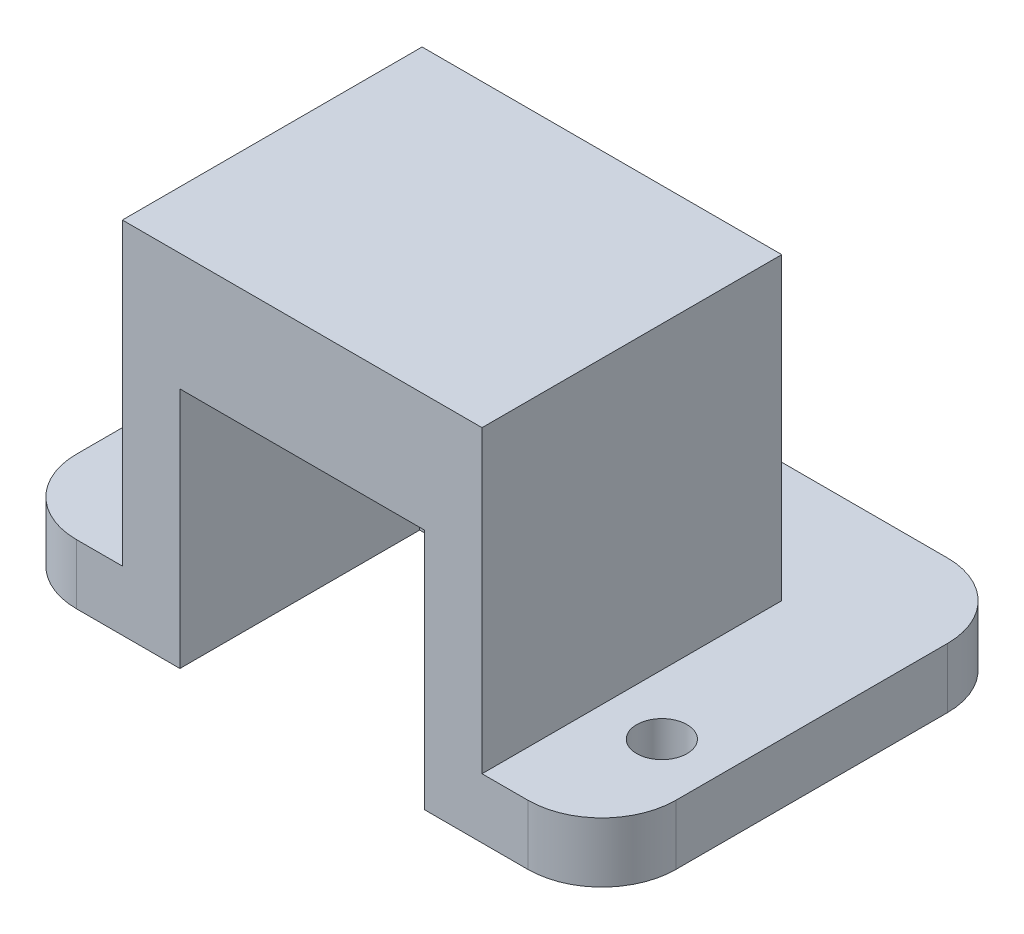
from build123d import *

# Parameters (mm, degrees)
SKETCH_1_W          = 30
SKETCH_1_H          = 30
EXTRUDE_1_DEPTH     = 5
SKETCH_2_W          = 30
SKETCH_2_H          = 5
EXTRUDE_2_DEPTH     = 10
SKETCH_3_R          = 2.1
CUT_EXTRUDE_1_DEPTH = 5
EXTRUDE_3_DEPTH     = 20
SKETCH_5_W          = 35
SKETCH_5_H          = 5
EXTRUDE_4_DEPTH     = 10
SKETCH_6_W          = 35
SKETCH_6_H          = 5
EXTRUDE_5_DEPTH     = 10
SKETCH_7_R          = 2.1
CUT_EXTRUDE_2_DEPTH = 10
FILLET_1_R          = 6.17
FILLET_2_R          = 6.17
FILLET_3_R          = 6.17
FILLET_4_R          = 6.17


with BuildPart() as part:
    # 스케치1 → 보스-돌출1 (new body)
    with BuildSketch(Plane.XY):
        Rectangle(SKETCH_1_W, SKETCH_1_H)
    extrude(amount=EXTRUDE_1_DEPTH)

    # 스케치2 → 보스-돌출2 (add)
    with BuildSketch(Plane(origin=(0, 0, 0), x_dir=(-1, 0, 0), z_dir=(0, 0, -1))):
        with Locations((0, -12.5)):
            Rectangle(SKETCH_2_W, SKETCH_2_H)
    extrude(amount=EXTRUDE_2_DEPTH)

    # 스케치3 → 컷-돌출1 (cut)
    with BuildSketch(Plane(origin=(0, -10, 0), x_dir=(1, 0, 0), z_dir=(0, 1, 0))):
        with Locations((0, 5)):
            Circle(SKETCH_3_R)
    extrude(amount=-CUT_EXTRUDE_1_DEPTH, mode=Mode.SUBTRACT)

    # 스케치4 → 보스-돌출3 (add)
    with BuildSketch(Plane.XY.offset(5)):
        Polygon((10.2, -15), (15, -15), (15, 15), (-15, 15), (-15, -15), (-10.2, -15), (-10.2, 5.2), (10.2, 5.2), align=None)
    extrude(amount=EXTRUDE_3_DEPTH)

    # 스케치5 → 보스-돌출4 (add)
    with BuildSketch(Plane.ZY.offset(15)):
        with Locations((7.5, -12.5)):
            Rectangle(SKETCH_5_W, SKETCH_5_H)
    extrude(amount=EXTRUDE_4_DEPTH)

    # 스케치6 → 보스-돌출5 (add)
    with BuildSketch(Plane(origin=(15, 0, 0), x_dir=(0, 0, -1), z_dir=(1, 0, 0))):
        with Locations((-7.5, -12.5)):
            Rectangle(SKETCH_6_W, SKETCH_6_H)
    extrude(amount=EXTRUDE_5_DEPTH)

    # 스케치7 → 컷-돌출2 (cut)
    with BuildSketch(Plane(origin=(0, -10, 0), x_dir=(1, 0, 0), z_dir=(0, 1, 0))):
        with Locations((-20, -15)):
            Circle(SKETCH_7_R)
        with Locations((20, -15)):
            Circle(SKETCH_7_R)
    extrude(amount=-CUT_EXTRUDE_2_DEPTH, mode=Mode.SUBTRACT)

    # 필렛1
    fillet_1_edges = [part.edges().sort_by_distance(p)[0] for p in [
        (25, -12.5, 25),
    ]]
    fillet(fillet_1_edges, radius=FILLET_1_R)

    # 필렛2
    fillet_2_edges = [part.edges().sort_by_distance(p)[0] for p in [
        (25, -12.5, -10),
    ]]
    fillet(fillet_2_edges, radius=FILLET_2_R)

    # 필렛3
    fillet_3_edges = [part.edges().sort_by_distance(p)[0] for p in [
        (-25, -12.5, 25),
    ]]
    fillet(fillet_3_edges, radius=FILLET_3_R)

    # 필렛4
    fillet_4_edges = [part.edges().sort_by_distance(p)[0] for p in [
        (-25, -12.5, -10),
    ]]
    fillet(fillet_4_edges, radius=FILLET_4_R)


solid = part.part
